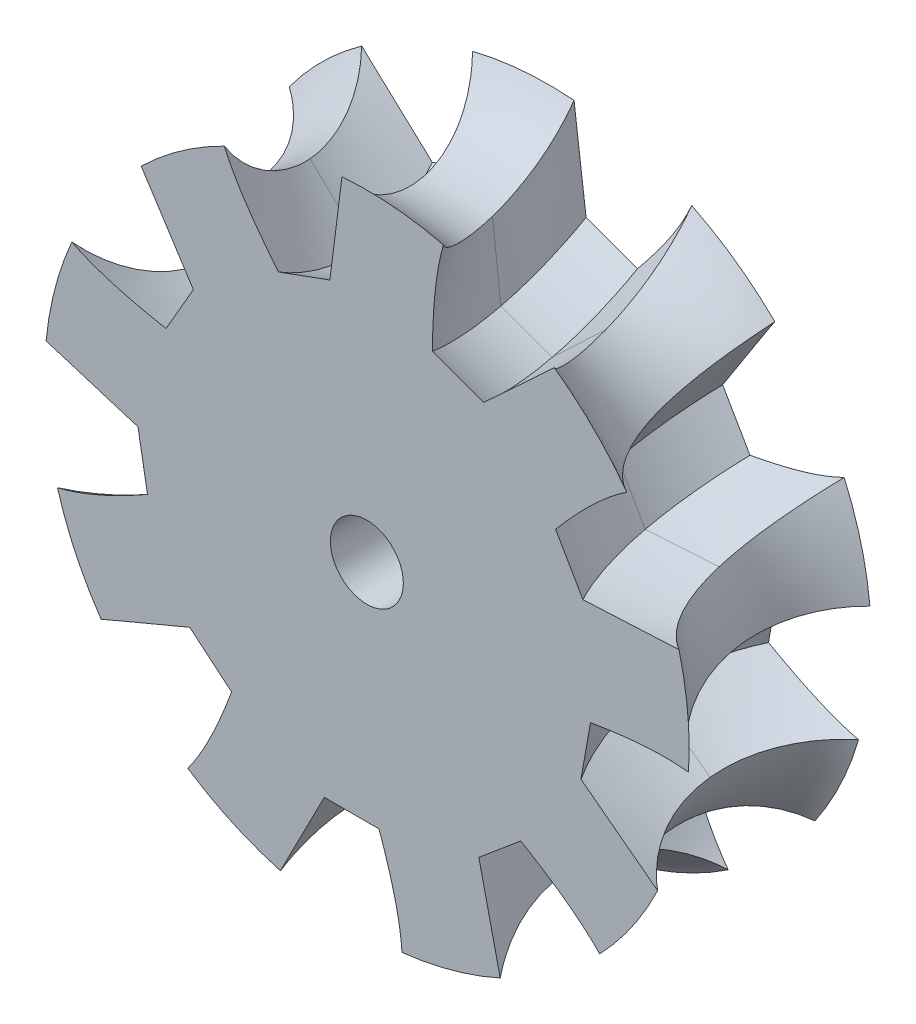
from build123d import *

# Parameters (mm, degrees)
SKETCH1_R              = 21
SKETCH1_R_2            = 2
BOSS_EXTRUDE1_DEPTH    = 10
CHAMFER1_SIZE          = 2
SKETCH2_R              = 6
CUT_SWEEP1_PITCH       = 10
CUT_SWEEP1_HEIGHT      = 2.5
CUT_SWEEP1_RADIUS      = 6
CUT_SWEEP1_START_ANGLE = -90
CUT_SWEEP2_PITCH       = 10
CUT_SWEEP2_HEIGHT      = 2.5
CUT_SWEEP2_RADIUS      = 6
CUT_SWEEP2_START_ANGLE = -90
CIRPATTERN1_COUNT      = 9


with BuildPart() as part:
    # Sketch1 → Boss-Extrude1 (new body)
    with BuildSketch(Plane.XY):
        Circle(SKETCH1_R)
        Circle(SKETCH1_R_2, mode=Mode.SUBTRACT)
    extrude(amount=BOSS_EXTRUDE1_DEPTH)

    # Chamfer1
    chamfer1_edges = [part.edges().sort_by_distance(p)[0] for p in [
        (-21, 0, 0),
        (-21, 0, 10),
    ]]
    chamfer(chamfer1_edges, length=CHAMFER1_SIZE)

    # Sketch2 → Cut-Revolve1 (revolve, cut)
    with BuildSketch(Plane(origin=(0, 0, 0), x_dir=(0, 0, -1), z_dir=(1, 0, 0)), mode=Mode.PRIVATE) as cut_revolve1_sk:
        with Locations((-5, -21)):
            Circle(SKETCH2_R)
    revolve(cut_revolve1_sk.sketch.rotate(Axis((0, 0, 0), (0, 0, -1)), 90), axis=Axis((0, 0, 0), (0, 0, -1)), mode=Mode.SUBTRACT)

    # Cut-Sweep1: sweep along a helix
    with BuildLine() as cut_sweep1_path:
        add(Helix(CUT_SWEEP1_PITCH, CUT_SWEEP1_HEIGHT, CUT_SWEEP1_RADIUS, center=(0, -21, 5), direction=(1, 0, 0), lefthand=True, mode=Mode.PRIVATE).rotate(Axis((0, -21, 5), (1, 0, 0)), CUT_SWEEP1_START_ANGLE))
    # Sketch5 → Cut-Sweep1 (sweep, cut)
    with BuildSketch(Plane.XY.offset(5)):
        Polygon((-1.5, -11), (1.5, -11), (3.5, -15), (3.5, -16.519818185), (-3.5, -16.519818185), (-3.5, -15), align=None)
    cut_sweep1 = sweep(path=cut_sweep1_path.line, is_frenet=True, mode=Mode.SUBTRACT)

    # Cut-Sweep2: sweep along a helix
    with BuildLine() as cut_sweep2_path:
        add(Helix(CUT_SWEEP2_PITCH, CUT_SWEEP2_HEIGHT, CUT_SWEEP2_RADIUS, center=(0, -21, 5), direction=(-1, 0, 0), lefthand=True, mode=Mode.PRIVATE).rotate(Axis((0, -21, 5), (-1, 0, 0)), CUT_SWEEP2_START_ANGLE))
    # Sketch7 → Cut-Sweep2 (sweep, cut)
    with BuildSketch(Plane.XY.offset(5)):
        Polygon((1.5, -11), (-1.5, -11), (-3.5, -15), (-3.5, -16.519818185), (3.5, -16.519818185), (3.5, -15), align=None)
    cut_sweep2 = sweep(path=cut_sweep2_path.line, is_frenet=True, mode=Mode.SUBTRACT)

    # CirPattern1: Cut-Sweep1, Cut-Sweep2 ×9 about axis
    cirpattern1_axis = Axis((0, 0, 10), (0, 0, -1))
    add([cut_sweep1.rotate(cirpattern1_axis, i * 360 / CIRPATTERN1_COUNT) for i in range(1, CIRPATTERN1_COUNT)], mode=Mode.SUBTRACT)
    add([cut_sweep2.rotate(cirpattern1_axis, i * 360 / CIRPATTERN1_COUNT) for i in range(1, CIRPATTERN1_COUNT)], mode=Mode.SUBTRACT)


solid = part.part
